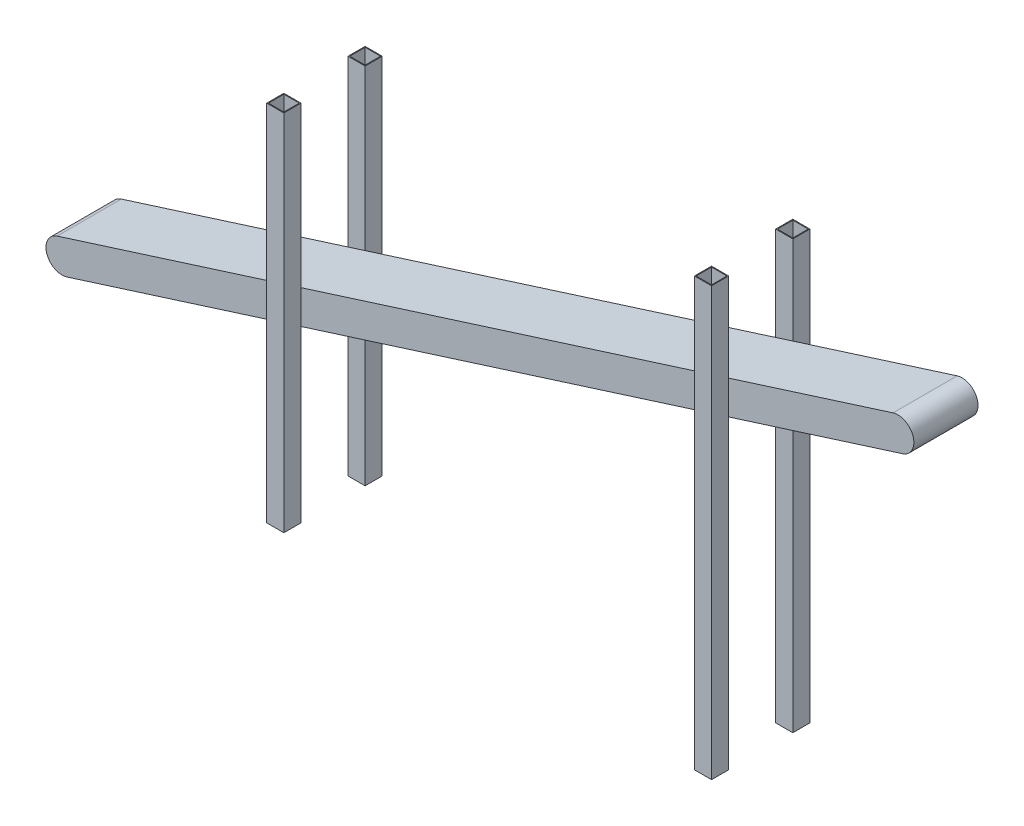
from build123d import *

# Parameters (mm, degrees)
BOSS_EXTRUDE1_DEPTH = 150
SKETCH3_W           = 40
SKETCH3_H           = 40
SKETCH3_W_2         = 36
SKETCH3_H_2         = 36
BOSS_EXTRUDE2_DEPTH = 850
SKETCH4_W           = 40
SKETCH4_H           = 40
SKETCH4_W_2         = 36
SKETCH4_H_2         = 36
BOSS_EXTRUDE3_DEPTH = 1000


with BuildPart() as part:
    # Sketch1 → Boss-Extrude1 (new body)
    with BuildSketch(Plane.XY):
        with BuildLine():
            Line((-11.326300276, 295.748635247), (1942.932426579, 914.919717023))
            ThreePointArc((1942.932426579, 914.919717023), (1990.007362103, 890.497382052), (1965.585027132, 843.422446529))
            Line((1965.585027132, 843.422446529), (11.326300276, 224.251364753))
            ThreePointArc((11.326300276, 224.251364753), (-35.748635247, 248.673699724), (-11.326300276, 295.748635247))
        make_face()
    extrude(amount=BOSS_EXTRUDE1_DEPTH)

    # Sketch3 → Boss-Extrude2 (add)
    with BuildSketch(Plane(origin=(0, 0, 0), x_dir=(1, 0, 0), z_dir=(0, 1, 0))):
        with Locations((538.673699724, 20)):
            Rectangle(SKETCH3_W, SKETCH3_H)
        with Locations((538.673699724, 20)):
            Rectangle(SKETCH3_W_2, SKETCH3_H_2, mode=Mode.SUBTRACT)
        with Locations((538.673699724, -170)):
            Rectangle(SKETCH3_W, SKETCH3_H)
        with Locations((538.673699724, -170)):
            Rectangle(SKETCH3_W_2, SKETCH3_H_2, mode=Mode.SUBTRACT)
    extrude(amount=BOSS_EXTRUDE2_DEPTH)

    # Sketch4 → Boss-Extrude3 (add)
    with BuildSketch(Plane(origin=(0, 0, 0), x_dir=(1, 0, 0), z_dir=(0, 1, 0))):
        with Locations((1538.673699724, 20)):
            Rectangle(SKETCH4_W, SKETCH4_H)
        with Locations((1538.673699724, 20)):
            Rectangle(SKETCH4_W_2, SKETCH4_H_2, mode=Mode.SUBTRACT)
        with Locations((1538.673699724, -170)):
            Rectangle(SKETCH4_W, SKETCH4_H)
        with Locations((1538.673699724, -170)):
            Rectangle(SKETCH4_W_2, SKETCH4_H_2, mode=Mode.SUBTRACT)
    extrude(amount=BOSS_EXTRUDE3_DEPTH)


solid = part.part
